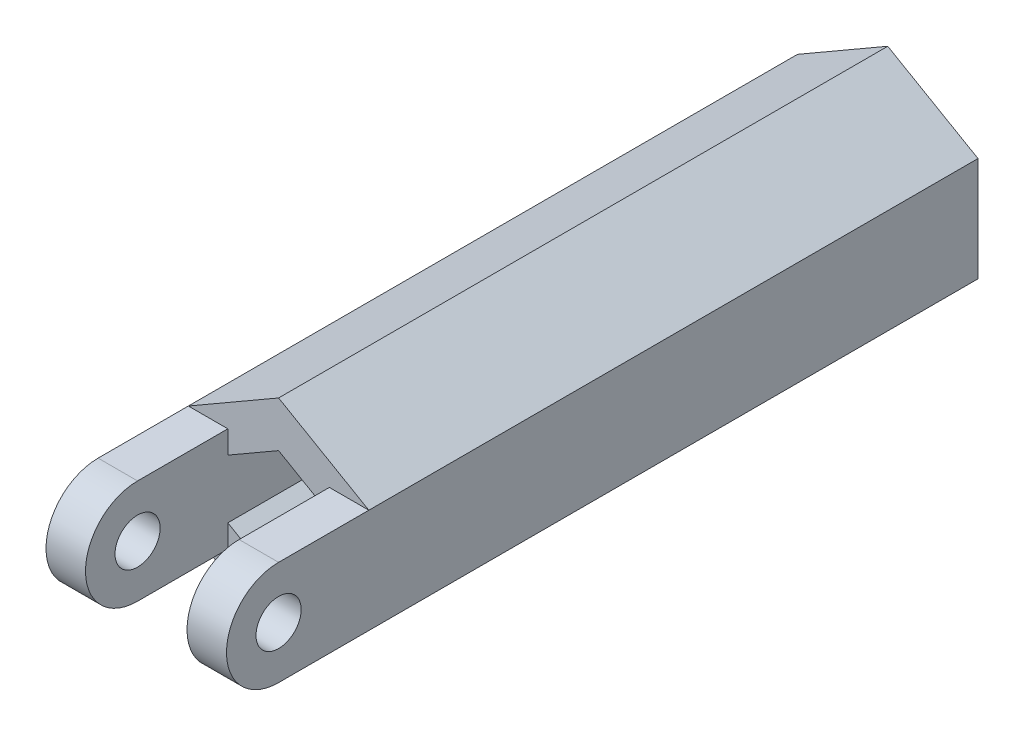
from build123d import *

# Parameters (mm, degrees)
EXTRUDE_1_DEPTH = 25
SKETCH_2_R      = 1.25
EXTRUDE_2_DEPTH = 2
SKETCH_3_R      = 1
EXTRUDE_3_DEPTH = 1.75
SKETCH_4_R      = 1
EXTRUDE_4_DEPTH = 1.75


with BuildPart() as part:
    # 스케치1 → 보스-돌출1 (new body)
    with BuildSketch(Plane.XY):
        Polygon((0, 4.618802154), (-4, 2.309401077), (-4, -2.309401077), (0, -4.618802154), (4, -2.309401077), (4, 2.309401077), align=None)
        Polygon((0, 2.598076211), (-2.25, 1.299038106), (-2.25, -1.299038106), (0, -2.598076211), (2.25, -1.299038106), (2.25, 1.299038106), align=None, mode=Mode.SUBTRACT)
    extrude(amount=EXTRUDE_1_DEPTH)

    # 스케치2 → 보스-돌출2 (add)
    with BuildSketch(Plane(origin=(0, 0, 0), x_dir=(-1, 0, 0), z_dir=(0, 0, -1))):
        Polygon((0, 4.618802154), (-4, 2.309401077), (-4, -2.309401077), (0, -4.618802154), (4, -2.309401077), (4, 2.309401077), align=None)
        Circle(SKETCH_2_R, mode=Mode.SUBTRACT)
    extrude(amount=EXTRUDE_2_DEPTH)

    # 스케치3 → 보스-돌출3 (add)
    with BuildSketch(Plane.ZY.offset(4)):
        with BuildLine():
            Line((25, 2.309401077), (29, 2.309401077))
            ThreePointArc((29, 2.309401077), (31.309401077, 0), (29, -2.309401077))
            Line((29, -2.309401077), (25, -2.309401077))
            Line((25, -2.309401077), (25, 2.309401077))
        make_face()
        with Locations((29, 0)):
            Circle(SKETCH_3_R, mode=Mode.SUBTRACT)
    extrude(amount=-EXTRUDE_3_DEPTH)

    # 스케치4 → 보스-돌출4 (add)
    with BuildSketch(Plane(origin=(4, 0, 0), x_dir=(0, 0, -1), z_dir=(1, 0, 0))):
        with BuildLine():
            Line((-29, 2.309401077), (-25, 2.309401077))
            Line((-25, 2.309401077), (-25, -2.309401077))
            Line((-25, -2.309401077), (-29, -2.309401077))
            ThreePointArc((-29, -2.309401077), (-31.309401077, 0), (-29, 2.309401077))
        make_face()
        with Locations((-29, 0)):
            Circle(SKETCH_4_R, mode=Mode.SUBTRACT)
    extrude(amount=-EXTRUDE_4_DEPTH)


solid = part.part
